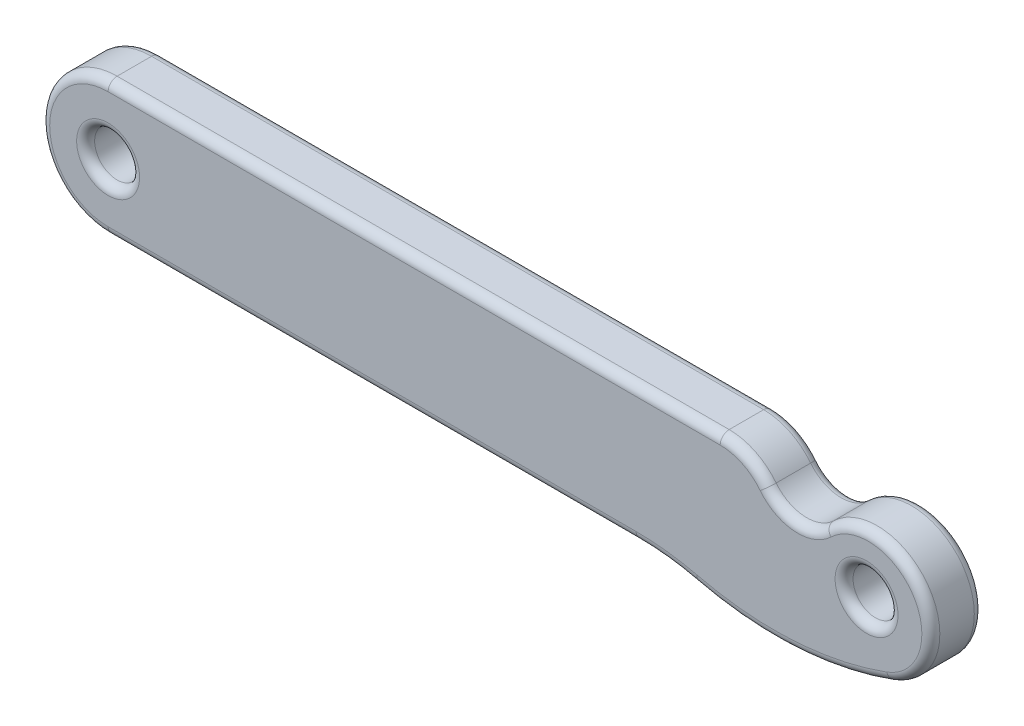
from build123d import *

# Parameters (mm, degrees)
SKETCH1_R           = 0.75
BOSS_EXTRUDE1_DEPTH = 1.75
CUT_EXTRUDE1_DEPTH  = 2.75
BOSS_EXTRUDE2_DEPTH = 1.75
FILLET1_R           = 0.3


with BuildPart() as part:
    # Sketch1 → Boss-Extrude1 (new body)
    with BuildSketch(Plane.XY):
        with BuildLine():
            Line((0, 2.25), (25.3139123, 2.25))
            ThreePointArc((25.3139123, 2.25), (27.5639123, 0), (25.3139123, -2.25))
            Line((25.3139123, -2.25), (0, -2.25))
            ThreePointArc((0, -2.25), (-2.25, 0), (0, 2.25))
        make_face()
        Circle(SKETCH1_R, mode=Mode.SUBTRACT)
        with Locations((25.3139123, 0)):
            Circle(SKETCH1_R, mode=Mode.SUBTRACT)
    extrude(amount=BOSS_EXTRUDE1_DEPTH)

    # Sketch3 → Cut-Extrude1 (cut, through all)
    with BuildSketch(Plane.XY.offset(1.75)):
        with BuildLine():
            Line((20.428705222, 2.25), (19.342677146, 2.25))
            Line((19.342677146, 2.25), (23.387436759, 7.422260387))
            Line((23.387436759, 7.422260387), (32.371586903, 3.422864517))
            Line((32.371586903, 3.422864517), (28.657239067, -4.174979021))
            Line((28.657239067, -4.174979021), (25.048377489, -2.234276452))
            ThreePointArc((25.048377489, -2.234276452), (25.575200601, -2.234777041), (26.087699031, -2.112759829))
            ThreePointArc((26.087699031, -2.112759829), (27.142254835, 0.959406624), (23.918802571, 1.358969087))
            ThreePointArc((23.918802571, 1.358969087), (22.929300966, 0.999117226), (21.997860665, 1.490060964))
            ThreePointArc((21.997860665, 1.490060964), (21.300450044, 2.050016934), (20.428705222, 2.25))
        make_face()
    extrude(amount=-CUT_EXTRUDE1_DEPTH, mode=Mode.SUBTRACT)

    # Sketch4 → Boss-Extrude2 (add)
    with BuildSketch(Plane.XY.offset(1.75)):
        with BuildLine():
            Line((17.62318329, -2.25), (26.087699031, -2.112759829))
            ThreePointArc((26.087699031, -2.112759829), (22.868792436, -2.779110617), (19.594871531, -2.484449879))
            ThreePointArc((19.594871531, -2.484449879), (18.61597245, -2.308818201), (17.62318329, -2.25))
        make_face()
    extrude(amount=-BOSS_EXTRUDE2_DEPTH)

    # Fillet1
    fillet1_edges = [part.edges().sort_by_distance(p)[0] for p in [
        (-0.75, 0, 0),
        (-0.75, 0, 1.75),
        (24.5639123, 0, 0),
        (24.5639123, 0, 1.75),
        (10.214352611, 2.25, 0),
        (10.214352611, 2.25, 1.75),
        (27.142254835, 0.959406624, 1.75),
        (21.300450044, 2.050016934, 1.75),
        (22.929300966, 0.999117226, 1.75),
        (27.142254835, 0.959406624, 0),
        (22.929300966, 0.999117226, 0),
        (21.300450044, 2.050016934, 0),
        (-2.25, 0, 1.75),
        (8.811591645, -2.25, 0),
        (-2.25, 0, 0),
        (18.61597245, -2.308818201, 1.75),
        (22.868792436, -2.779110617, 1.75),
        (22.868792436, -2.779110617, 0),
        (18.61597245, -2.308818201, 0),
        (8.811591645, -2.25, 1.75),
    ]]
    fillet(fillet1_edges, radius=FILLET1_R)


solid = part.part
